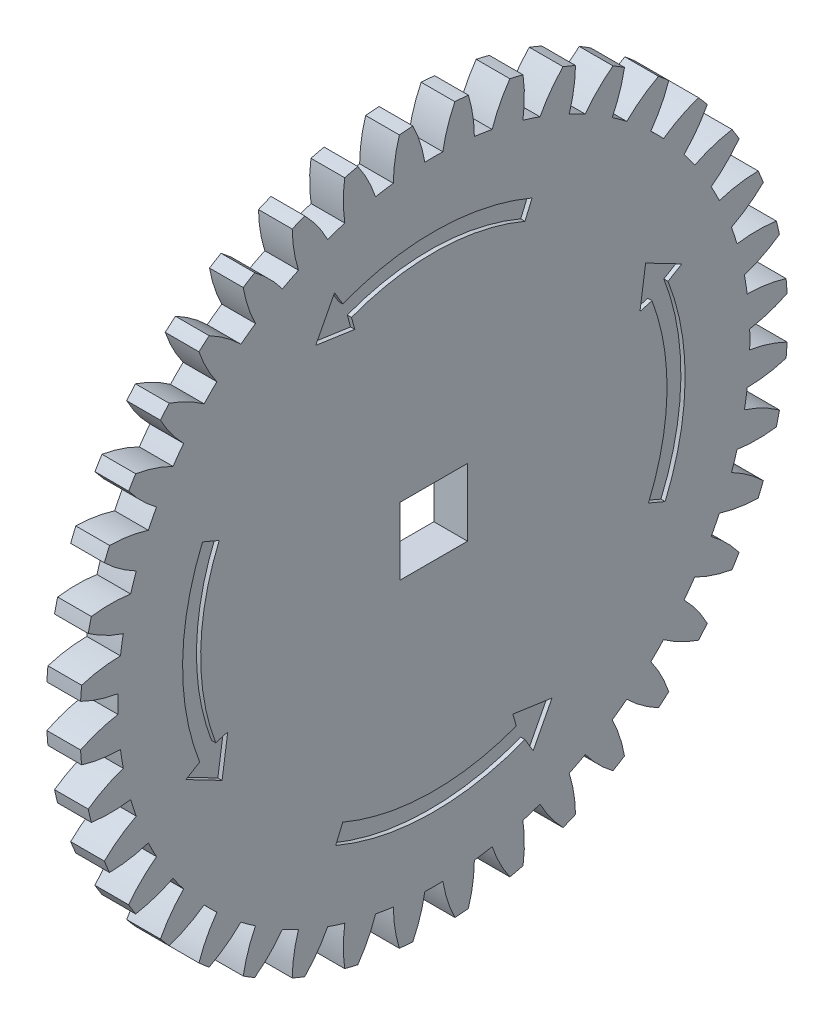
from build123d import *

# Parameters (mm, degrees)
BASPROSKE_W         = 4
BASPROSKE_H         = 42
TOOTHCUT_DEPTH      = 60.531504265
TEETHCUTS_COUNT     = 40
TEETHCUTS_ANGLE     = 351
SKETCH_1_W          = 8
SKETCH_1_H          = 8
CUT_EXTRUDE_1_DEPTH = 60.426818094
CUT_EXTRUDE1_DEPTH  = 0.5
CIRPATTERN1_COUNT   = 4


with BuildPart() as part:
    # BasProSke → Base-Revolve (revolve)
    with BuildSketch(Plane(origin=(0, 0, 0), x_dir=(1, 0, 0), z_dir=(0, 1, 0))):
        with Locations((2, 21)):
            Rectangle(BASPROSKE_W, BASPROSKE_H)
    revolve(axis=Axis((-10, 0, 0), (1, 0, 0)))

    # TooCutSke → ToothCut (cut, through all)
    with BuildSketch(Plane(origin=(0, 0, 0), x_dir=(0, 0, -1), z_dir=(1, 0, 0))):
        with BuildLine():
            ThreePointArc((1.069221139, 37.483753376), (0, 37.499), (-1.069221139, 37.483753376))
            ThreePointArc((-1.069221139, 37.483753376), (-1.623716038, 39.770155553), (-2.507504748, 41.950526398))
            ThreePointArc((-2.507504748, 41.950526398), (0, 42.0254), (2.507504748, 41.950526398))
            ThreePointArc((2.507504748, 41.950526398), (1.623716038, 39.770155553), (1.069221139, 37.483753376))
        make_face()
    toothcut = extrude(amount=TOOTHCUT_DEPTH, mode=Mode.SUBTRACT)

    # TeethCuts: ToothCut ×40 about axis
    teethcuts_axis = Axis((-10, 0, 0), (1, 0, 0))
    for i in range(1, TEETHCUTS_COUNT):
        add(toothcut.rotate(teethcuts_axis, i * TEETHCUTS_ANGLE / (TEETHCUTS_COUNT - 1)), mode=Mode.SUBTRACT)

    # 草图1 → 切除-拉伸1 (cut, through all)
    with BuildSketch(Plane(origin=(4, 0, 0), x_dir=(0, 0, -1), z_dir=(1, 0, 0))):
        Rectangle(SKETCH_1_W, SKETCH_1_H)
    extrude(amount=-CUT_EXTRUDE_1_DEPTH, mode=Mode.SUBTRACT)

    # Sketch1 → Cut-Extrude1 (cut)
    with BuildSketch(Plane(origin=(4, 0, 0), x_dir=(0, 0, -1), z_dir=(1, 0, 0))):
        with BuildLine():
            Line((27.44994676, -11.650994809), (25.473105756, -10.811934374))
            ThreePointArc((25.473105756, -10.811934374), (27.667043992, -0.558317583), (25.888556916, 9.775462269))
            Line((25.888556916, 9.775462269), (24.461664354, 9.382793373))
            Line((24.461664354, 9.382793373), (25.13416514, 14.018775822))
            Line((25.13416514, 14.018775822), (29.429658815, 11.785678551))
            Line((29.429658815, 11.785678551), (27.791137657, 10.811934374))
            ThreePointArc((27.791137657, 10.811934374), (29.816776298, -0.452888961), (27.44994676, -11.650994809))
        make_face()
    cut_extrude1 = extrude(amount=-CUT_EXTRUDE1_DEPTH, mode=Mode.SUBTRACT)

    # CirPattern1: Cut-Extrude1 ×4 about axis
    cirpattern1_axis = Axis((80.9, 0, 0), (-1, 0, 0))
    for i in range(1, CIRPATTERN1_COUNT):
        add(cut_extrude1.rotate(cirpattern1_axis, i * 360 / CIRPATTERN1_COUNT), mode=Mode.SUBTRACT)


solid = part.part
